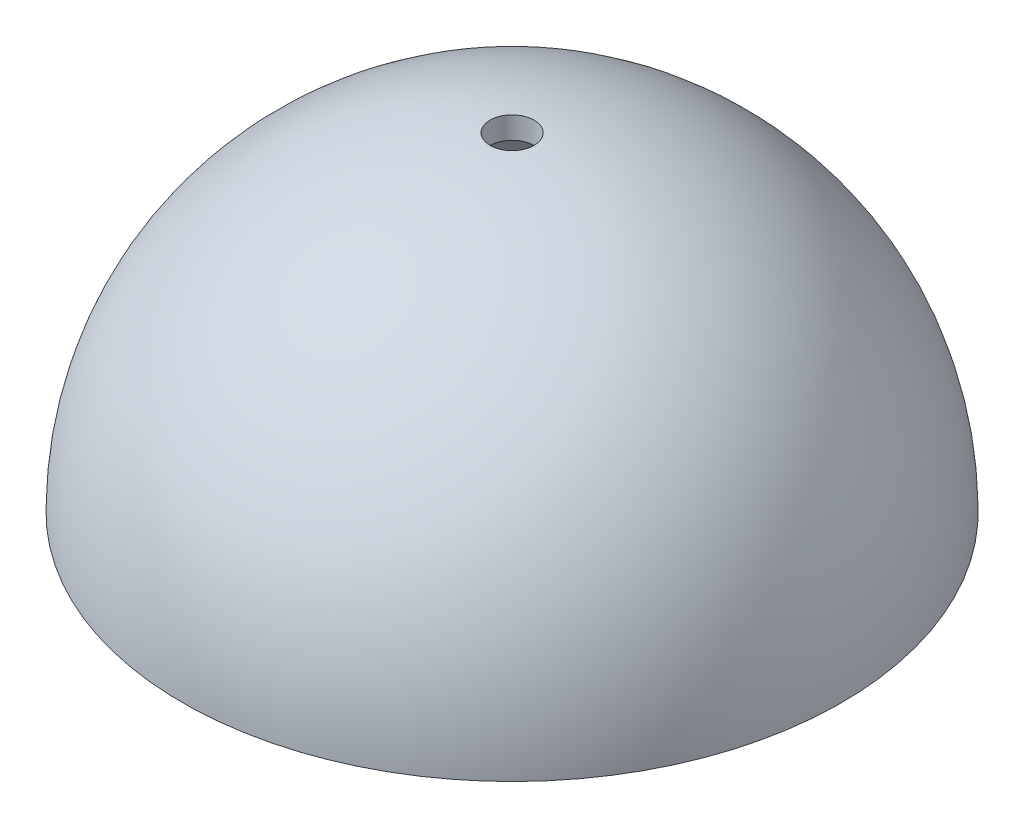
from build123d import *

# Parameters (mm, degrees)
SHELL1_T                = -10
SKETCH2_R               = 10
CUT_EXTRUDE3_DEPTH      = 260.807621135
CUT_EXTRUDE3_DEPTH_BACK = 260.807621135


with BuildPart() as part:
    # Sketch1 → Revolve1 (revolve)
    with BuildSketch(Plane.XY):
        with BuildLine():
            Line((0, 0), (0, 150))
            ThreePointArc((0, 150), (-106.066017178, 106.066017178), (-150, 0))
            Line((-150, 0), (0, 0))
        make_face()
    revolve(axis=Axis((0, 0, 0), (0, 1, 0)))

    # Shell1
    shell1_openings = [part.faces().sort_by_distance(p)[0] for p in [
        (0, 0, 0),
    ]]
    offset(amount=SHELL1_T, openings=shell1_openings, kind=Kind.INTERSECTION)

    # Sketch2 → Cut-Extrude3 (cut, two sides)
    with BuildSketch(Plane(origin=(0, 0, 0), x_dir=(1, 0, 0), z_dir=(0, 1, 0))) as cut_extrude3_sk:
        with Locations(Location((0, 0, 0), (0, 0, 270))):
            Circle(SKETCH2_R)
    extrude(amount=CUT_EXTRUDE3_DEPTH, mode=Mode.SUBTRACT)
    extrude(cut_extrude3_sk.sketch, amount=-CUT_EXTRUDE3_DEPTH_BACK, mode=Mode.SUBTRACT)


solid = part.part
